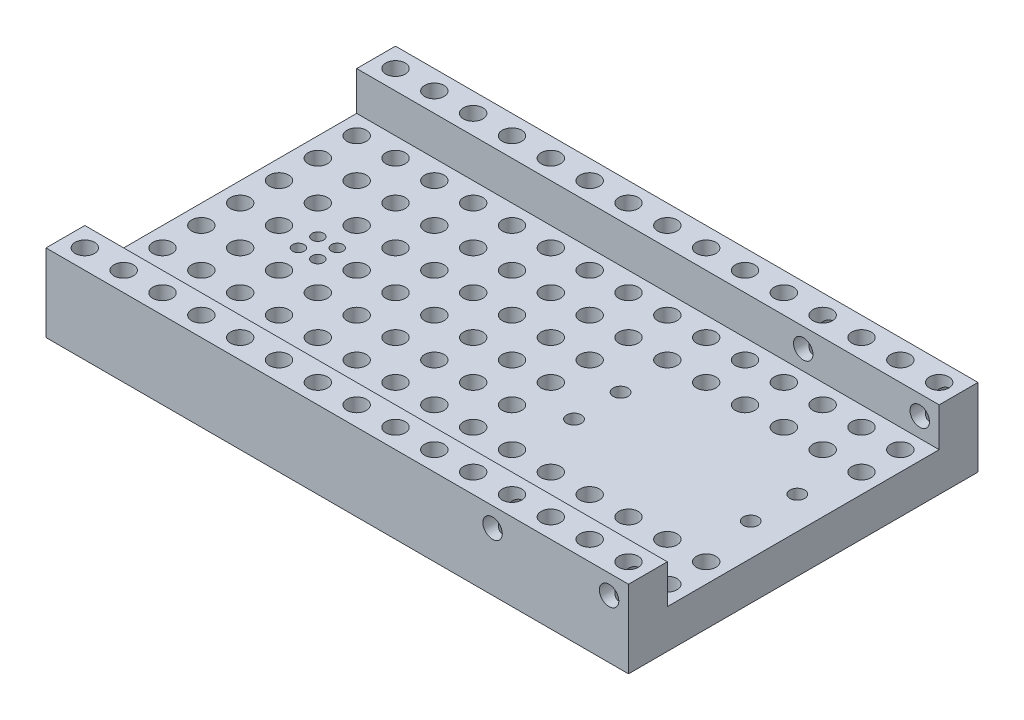
from build123d import *

# Parameters (mm, degrees)
SKETCH1_W               = 150
SKETCH1_H               = 10
SKETCH1_R               = 2.5
BOSS_EXTRUDE1_DEPTH     = 20
BOSS_EXTRUDE1_2_DEPTH   = 20
SKETCH1_3_W             = 150
SKETCH1_3_H             = 70
SKETCH1_3_R             = 2.5
SKETCH1_3_R_2           = 1.5
SKETCH1_3_W_2           = 51
SKETCH1_3_H_2           = 21
BOSS_EXTRUDE2_DEPTH     = 10
SKETCH3_R               = 2.5
CUT_EXTRUDE1_DEPTH      = 81
CUT_EXTRUDE1_DEPTH_BACK = 11
SKETCH1_4_W             = 51
SKETCH1_4_H             = 21
SKETCH1_4_R             = 1.9
BOSS_EXTRUDE3_DEPTH     = 10


with BuildPart() as part:
    # Sketch1 → Boss-Extrude1 (new body)
    with BuildSketch(Plane(origin=(0, 0, 0), x_dir=(1, 0, 0), z_dir=(0, 1, 0))):
        with Locations((-15.172413793, 63.476267415)):
            Rectangle(SKETCH1_W, SKETCH1_H)
        with Locations((-85.172413793, 63.476267415)):
            Circle(SKETCH1_R, mode=Mode.SUBTRACT)
        with Locations((-75.172413793, 63.476267415)):
            Circle(SKETCH1_R, mode=Mode.SUBTRACT)
        with Locations((-65.172413793, 63.476267415)):
            Circle(SKETCH1_R, mode=Mode.SUBTRACT)
        with Locations((-55.172413793, 63.476267415)):
            Circle(SKETCH1_R, mode=Mode.SUBTRACT)
        with Locations((-45.172413793, 63.476267415)):
            Circle(SKETCH1_R, mode=Mode.SUBTRACT)
        with Locations((-35.172413793, 63.476267415)):
            Circle(SKETCH1_R, mode=Mode.SUBTRACT)
        with Locations((-25.172413793, 63.476267415)):
            Circle(SKETCH1_R, mode=Mode.SUBTRACT)
        with Locations((-15.172413793, 63.476267415)):
            Circle(SKETCH1_R, mode=Mode.SUBTRACT)
        with Locations((-5.172413793, 63.476267415)):
            Circle(SKETCH1_R, mode=Mode.SUBTRACT)
        with Locations((4.827586207, 63.476267415)):
            Circle(SKETCH1_R, mode=Mode.SUBTRACT)
        with Locations((14.827586207, 63.476267415)):
            Circle(SKETCH1_R, mode=Mode.SUBTRACT)
        with Locations((24.827586207, 63.476267415)):
            Circle(SKETCH1_R, mode=Mode.SUBTRACT)
        with Locations((34.827586207, 63.476267415)):
            Circle(SKETCH1_R, mode=Mode.SUBTRACT)
        with Locations((44.827586207, 63.476267415)):
            Circle(SKETCH1_R, mode=Mode.SUBTRACT)
        with Locations((54.827586207, 63.476267415)):
            Circle(SKETCH1_R, mode=Mode.SUBTRACT)
    extrude(amount=BOSS_EXTRUDE1_DEPTH)



with BuildPart() as body_2:
    # Sketch1 → Boss-Extrude1 2 (new body)
    with BuildSketch(Plane(origin=(0, 0, 0), x_dir=(1, 0, 0), z_dir=(0, 1, 0))):
        with Locations((-15.172413793, -16.523732585)):
            Rectangle(SKETCH1_W, SKETCH1_H)
        with Locations((-85.172413793, -16.523732585)):
            Circle(SKETCH1_R, mode=Mode.SUBTRACT)
        with Locations((-75.172413793, -16.523732585)):
            Circle(SKETCH1_R, mode=Mode.SUBTRACT)
        with Locations((-65.172413793, -16.523732585)):
            Circle(SKETCH1_R, mode=Mode.SUBTRACT)
        with Locations((-55.172413793, -16.523732585)):
            Circle(SKETCH1_R, mode=Mode.SUBTRACT)
        with Locations((-45.172413793, -16.523732585)):
            Circle(SKETCH1_R, mode=Mode.SUBTRACT)
        with Locations((-35.172413793, -16.523732585)):
            Circle(SKETCH1_R, mode=Mode.SUBTRACT)
        with Locations((-25.172413793, -16.523732585)):
            Circle(SKETCH1_R, mode=Mode.SUBTRACT)
        with Locations((-15.172413793, -16.523732585)):
            Circle(SKETCH1_R, mode=Mode.SUBTRACT)
        with Locations((-5.172413793, -16.523732585)):
            Circle(SKETCH1_R, mode=Mode.SUBTRACT)
        with Locations((4.827586207, -16.523732585)):
            Circle(SKETCH1_R, mode=Mode.SUBTRACT)
        with Locations((14.827586207, -16.523732585)):
            Circle(SKETCH1_R, mode=Mode.SUBTRACT)
        with Locations((24.827586207, -16.523732585)):
            Circle(SKETCH1_R, mode=Mode.SUBTRACT)
        with Locations((34.827586207, -16.523732585)):
            Circle(SKETCH1_R, mode=Mode.SUBTRACT)
        with Locations((44.827586207, -16.523732585)):
            Circle(SKETCH1_R, mode=Mode.SUBTRACT)
        with Locations((54.827586207, -16.523732585)):
            Circle(SKETCH1_R, mode=Mode.SUBTRACT)
    extrude(amount=BOSS_EXTRUDE1_2_DEPTH)


with BuildPart() as part_1:
    add(part.part)

    add(body_2.part)  # Boss-Extrude2 merges body 2
    # Sketch1_3 → Boss-Extrude2 (add)
    with BuildSketch(Plane(origin=(0, 0, 0), x_dir=(1, 0, 0), z_dir=(0, 1, 0))):
        with Locations((-15.172413793, 23.476267415)):
            Rectangle(SKETCH1_3_W, SKETCH1_3_H)
        with Locations((-85.172413793, -6.523732585)):
            Circle(SKETCH1_3_R, mode=Mode.SUBTRACT)
        with Locations((-75.172413793, -6.523732585)):
            Circle(SKETCH1_3_R, mode=Mode.SUBTRACT)
        with Locations((-65.172413793, -6.523732585)):
            Circle(SKETCH1_3_R, mode=Mode.SUBTRACT)
        with Locations((-55.172413793, -6.523732585)):
            Circle(SKETCH1_3_R, mode=Mode.SUBTRACT)
        with Locations((-45.172413793, -6.523732585)):
            Circle(SKETCH1_3_R, mode=Mode.SUBTRACT)
        with Locations((-35.172413793, -6.523732585)):
            Circle(SKETCH1_3_R, mode=Mode.SUBTRACT)
        with Locations((-25.172413793, -6.523732585)):
            Circle(SKETCH1_3_R, mode=Mode.SUBTRACT)
        with Locations((-15.172413793, -6.523732585)):
            Circle(SKETCH1_3_R, mode=Mode.SUBTRACT)
        with Locations((-85.172413793, 3.476267415)):
            Circle(SKETCH1_3_R, mode=Mode.SUBTRACT)
        with Locations((-75.172413793, 3.476267415)):
            Circle(SKETCH1_3_R, mode=Mode.SUBTRACT)
        with Locations((-85.172413793, 13.476267415)):
            Circle(SKETCH1_3_R, mode=Mode.SUBTRACT)
        with Locations((-75.172413793, 13.476267415)):
            Circle(SKETCH1_3_R, mode=Mode.SUBTRACT)
        with Locations((-65.172413793, 3.476267415)):
            Circle(SKETCH1_3_R, mode=Mode.SUBTRACT)
        with Locations((-55.172413793, 3.476267415)):
            Circle(SKETCH1_3_R, mode=Mode.SUBTRACT)
        with Locations((-65.172413793, 13.476267415)):
            Circle(SKETCH1_3_R, mode=Mode.SUBTRACT)
        with Locations((-55.172413793, 13.476267415)):
            Circle(SKETCH1_3_R, mode=Mode.SUBTRACT)
        with Locations((-85.172413793, 23.476267415)):
            Circle(SKETCH1_3_R, mode=Mode.SUBTRACT)
        with Locations((-75.172413793, 23.476267415)):
            Circle(SKETCH1_3_R, mode=Mode.SUBTRACT)
        with Locations((-67.672413793, 25.976267415)):
            Circle(SKETCH1_3_R_2, mode=Mode.SUBTRACT)
        with Locations((-62.672413793, 25.976267415)):
            Circle(SKETCH1_3_R_2, mode=Mode.SUBTRACT)
        with Locations((-62.672413793, 20.976267415)):
            Circle(SKETCH1_3_R_2, mode=Mode.SUBTRACT)
        with Locations((-67.672413793, 20.976267415)):
            Circle(SKETCH1_3_R_2, mode=Mode.SUBTRACT)
        with Locations((-55.172413793, 23.476267415)):
            Circle(SKETCH1_3_R, mode=Mode.SUBTRACT)
        with Locations((-45.172413793, 3.476267415)):
            Circle(SKETCH1_3_R, mode=Mode.SUBTRACT)
        with Locations((-35.172413793, 3.476267415)):
            Circle(SKETCH1_3_R, mode=Mode.SUBTRACT)
        with Locations((-45.172413793, 13.476267415)):
            Circle(SKETCH1_3_R, mode=Mode.SUBTRACT)
        with Locations((-35.172413793, 13.476267415)):
            Circle(SKETCH1_3_R, mode=Mode.SUBTRACT)
        with Locations((-25.172413793, 3.476267415)):
            Circle(SKETCH1_3_R, mode=Mode.SUBTRACT)
        with Locations((-15.172413793, 3.476267415)):
            Circle(SKETCH1_3_R, mode=Mode.SUBTRACT)
        with Locations((-25.172413793, 13.476267415)):
            Circle(SKETCH1_3_R, mode=Mode.SUBTRACT)
        with Locations((-15.172413793, 13.476267415)):
            Circle(SKETCH1_3_R, mode=Mode.SUBTRACT)
        with Locations((-45.172413793, 23.476267415)):
            Circle(SKETCH1_3_R, mode=Mode.SUBTRACT)
        with Locations((-35.172413793, 23.476267415)):
            Circle(SKETCH1_3_R, mode=Mode.SUBTRACT)
        with Locations((-25.172413793, 23.476267415)):
            Circle(SKETCH1_3_R, mode=Mode.SUBTRACT)
        with Locations((-15.172413793, 23.476267415)):
            Circle(SKETCH1_3_R, mode=Mode.SUBTRACT)
        with Locations((-5.172413793, -6.523732585)):
            Circle(SKETCH1_3_R, mode=Mode.SUBTRACT)
        with Locations((4.827586207, -6.523732585)):
            Circle(SKETCH1_3_R, mode=Mode.SUBTRACT)
        with Locations((14.827586207, -6.523732585)):
            Circle(SKETCH1_3_R, mode=Mode.SUBTRACT)
        with Locations((24.827586207, -6.523732585)):
            Circle(SKETCH1_3_R, mode=Mode.SUBTRACT)
        with Locations((34.827586207, -6.523732585)):
            Circle(SKETCH1_3_R, mode=Mode.SUBTRACT)
        with Locations((44.827586207, -6.523732585)):
            Circle(SKETCH1_3_R, mode=Mode.SUBTRACT)
        with Locations((54.827586207, -6.523732585)):
            Circle(SKETCH1_3_R, mode=Mode.SUBTRACT)
        with Locations((-5.172413793, 3.476267415)):
            Circle(SKETCH1_3_R, mode=Mode.SUBTRACT)
        with Locations((-5.172413793, 13.476267415)):
            Circle(SKETCH1_3_R, mode=Mode.SUBTRACT)
        with Locations((4.827586207, 3.476267415)):
            Circle(SKETCH1_3_R, mode=Mode.SUBTRACT)
        with Locations((14.827586207, 3.476267415)):
            Circle(SKETCH1_3_R, mode=Mode.SUBTRACT)
        with Locations((-5.172413793, 23.476267415)):
            Circle(SKETCH1_3_R, mode=Mode.SUBTRACT)
        with Locations((24.827586207, 3.476267415)):
            Circle(SKETCH1_3_R, mode=Mode.SUBTRACT)
        with Locations((34.827586207, 3.476267415)):
            Circle(SKETCH1_3_R, mode=Mode.SUBTRACT)
        with Locations((44.827586207, 3.476267415)):
            Circle(SKETCH1_3_R, mode=Mode.SUBTRACT)
        with Locations((54.827586207, 3.476267415)):
            Circle(SKETCH1_3_R, mode=Mode.SUBTRACT)
        with Locations((28.494639931, 23.976267415)):
            Rectangle(SKETCH1_3_W_2, SKETCH1_3_H_2, mode=Mode.SUBTRACT)
        with Locations((-85.172413793, 33.476267415)):
            Circle(SKETCH1_3_R, mode=Mode.SUBTRACT)
        with Locations((-75.172413793, 33.476267415)):
            Circle(SKETCH1_3_R, mode=Mode.SUBTRACT)
        with Locations((-65.172413793, 33.476267415)):
            Circle(SKETCH1_3_R, mode=Mode.SUBTRACT)
        with Locations((-55.172413793, 33.476267415)):
            Circle(SKETCH1_3_R, mode=Mode.SUBTRACT)
        with Locations((-85.172413793, 43.476267415)):
            Circle(SKETCH1_3_R, mode=Mode.SUBTRACT)
        with Locations((-75.172413793, 43.476267415)):
            Circle(SKETCH1_3_R, mode=Mode.SUBTRACT)
        with Locations((-65.172413793, 43.476267415)):
            Circle(SKETCH1_3_R, mode=Mode.SUBTRACT)
        with Locations((-55.172413793, 43.476267415)):
            Circle(SKETCH1_3_R, mode=Mode.SUBTRACT)
        with Locations((-45.172413793, 33.476267415)):
            Circle(SKETCH1_3_R, mode=Mode.SUBTRACT)
        with Locations((-35.172413793, 33.476267415)):
            Circle(SKETCH1_3_R, mode=Mode.SUBTRACT)
        with Locations((-25.172413793, 33.476267415)):
            Circle(SKETCH1_3_R, mode=Mode.SUBTRACT)
        with Locations((-15.172413793, 33.476267415)):
            Circle(SKETCH1_3_R, mode=Mode.SUBTRACT)
        with Locations((-45.172413793, 43.476267415)):
            Circle(SKETCH1_3_R, mode=Mode.SUBTRACT)
        with Locations((-35.172413793, 43.476267415)):
            Circle(SKETCH1_3_R, mode=Mode.SUBTRACT)
        with Locations((-25.172413793, 43.476267415)):
            Circle(SKETCH1_3_R, mode=Mode.SUBTRACT)
        with Locations((-15.172413793, 43.476267415)):
            Circle(SKETCH1_3_R, mode=Mode.SUBTRACT)
        with Locations((-85.172413793, 53.476267415)):
            Circle(SKETCH1_3_R, mode=Mode.SUBTRACT)
        with Locations((-75.172413793, 53.476267415)):
            Circle(SKETCH1_3_R, mode=Mode.SUBTRACT)
        with Locations((-65.172413793, 53.476267415)):
            Circle(SKETCH1_3_R, mode=Mode.SUBTRACT)
        with Locations((-55.172413793, 53.476267415)):
            Circle(SKETCH1_3_R, mode=Mode.SUBTRACT)
        with Locations((-45.172413793, 53.476267415)):
            Circle(SKETCH1_3_R, mode=Mode.SUBTRACT)
        with Locations((-35.172413793, 53.476267415)):
            Circle(SKETCH1_3_R, mode=Mode.SUBTRACT)
        with Locations((-25.172413793, 53.476267415)):
            Circle(SKETCH1_3_R, mode=Mode.SUBTRACT)
        with Locations((-15.172413793, 53.476267415)):
            Circle(SKETCH1_3_R, mode=Mode.SUBTRACT)
        with Locations((-5.172413793, 33.476267415)):
            Circle(SKETCH1_3_R, mode=Mode.SUBTRACT)
        with Locations((-5.172413793, 43.476267415)):
            Circle(SKETCH1_3_R, mode=Mode.SUBTRACT)
        with Locations((4.827586207, 43.476267415)):
            Circle(SKETCH1_3_R, mode=Mode.SUBTRACT)
        with Locations((14.827586207, 43.476267415)):
            Circle(SKETCH1_3_R, mode=Mode.SUBTRACT)
        with Locations((24.827586207, 43.476267415)):
            Circle(SKETCH1_3_R, mode=Mode.SUBTRACT)
        with Locations((34.827586207, 43.476267415)):
            Circle(SKETCH1_3_R, mode=Mode.SUBTRACT)
        with Locations((44.827586207, 43.476267415)):
            Circle(SKETCH1_3_R, mode=Mode.SUBTRACT)
        with Locations((54.827586207, 43.476267415)):
            Circle(SKETCH1_3_R, mode=Mode.SUBTRACT)
        with Locations((-5.172413793, 53.476267415)):
            Circle(SKETCH1_3_R, mode=Mode.SUBTRACT)
        with Locations((4.827586207, 53.476267415)):
            Circle(SKETCH1_3_R, mode=Mode.SUBTRACT)
        with Locations((14.827586207, 53.476267415)):
            Circle(SKETCH1_3_R, mode=Mode.SUBTRACT)
        with Locations((24.827586207, 53.476267415)):
            Circle(SKETCH1_3_R, mode=Mode.SUBTRACT)
        with Locations((34.827586207, 53.476267415)):
            Circle(SKETCH1_3_R, mode=Mode.SUBTRACT)
        with Locations((44.827586207, 53.476267415)):
            Circle(SKETCH1_3_R, mode=Mode.SUBTRACT)
        with Locations((54.827586207, 53.476267415)):
            Circle(SKETCH1_3_R, mode=Mode.SUBTRACT)
    extrude(amount=BOSS_EXTRUDE2_DEPTH)

    # Sketch3 → Cut-Extrude1 (cut, two sides)
    with BuildSketch(Plane(origin=(0, 0, 11.523732585), x_dir=(-1, 0, 0), z_dir=(0, 0, -1))) as cut_extrude1_sk:
        with Locations((-24.827586207, 15)):
            Circle(SKETCH3_R)
        with Locations((-54.827586207, 15)):
            Circle(SKETCH3_R)
    extrude(amount=CUT_EXTRUDE1_DEPTH, mode=Mode.SUBTRACT)
    extrude(cut_extrude1_sk.sketch, amount=-CUT_EXTRUDE1_DEPTH_BACK, mode=Mode.SUBTRACT)

    # Sketch1_4 → Boss-Extrude3 (add)
    with BuildSketch(Plane(origin=(0, 0, 0), x_dir=(1, 0, 0), z_dir=(0, 1, 0))):
        with Locations((28.494639931, 23.976267415)):
            Rectangle(SKETCH1_4_W, SKETCH1_4_H)
        with Locations((51.494639931, 30.276267415)):
            Circle(SKETCH1_4_R, mode=Mode.SUBTRACT)
        with Locations((5.994639931, 30.276267415)):
            Circle(SKETCH1_4_R, mode=Mode.SUBTRACT)
        with Locations((5.994639931, 18.276267415)):
            Circle(SKETCH1_4_R, mode=Mode.SUBTRACT)
        with Locations((51.494639931, 18.276267415)):
            Circle(SKETCH1_4_R, mode=Mode.SUBTRACT)
    extrude(amount=BOSS_EXTRUDE3_DEPTH)


solid = part_1.part
